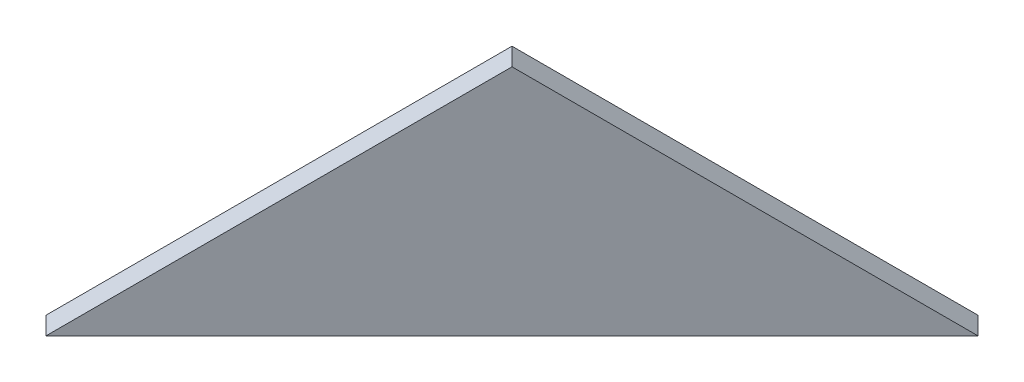
from build123d import *

# Parameters (mm, degrees)
BOSS_EXTRUDE1_DEPTH = 1.5


with BuildPart() as part:
    # Sketch1 → Boss-Extrude1 (new body, symmetric)
    with BuildSketch(Plane(origin=(80.401490288, 0, 80.401490288), x_dir=(0.707106781, 0, -0.707106781), z_dir=(0.707106781, 0, 0.707106781))):
        Polygon((0, -83.512342261), (-39.106591076, -111.164878), (39.106591076, -111.164878), align=None)
    extrude(amount=BOSS_EXTRUDE1_DEPTH, both=True)


solid = part.part
